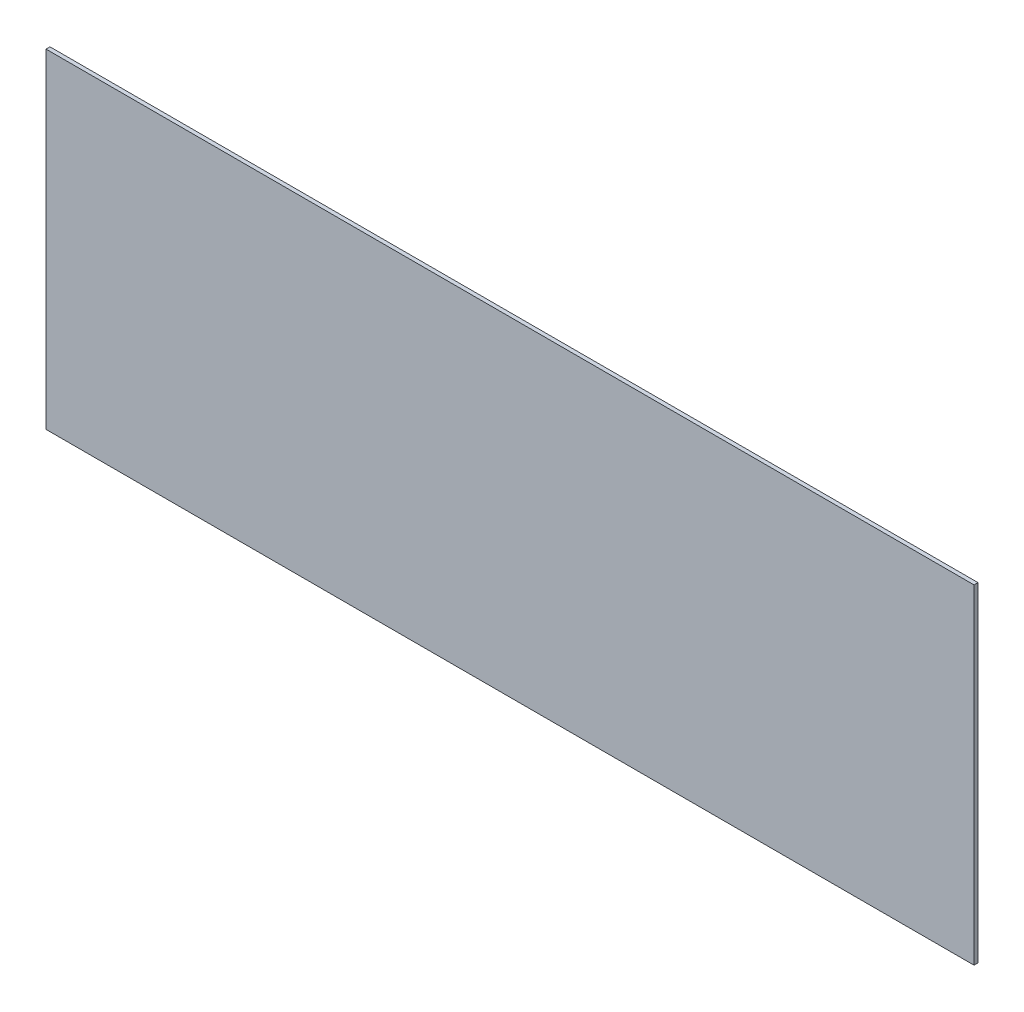
from build123d import *

# Parameters (mm, degrees)
SKETCH1_W           = 745
SKETCH1_H           = 264.4
BOSS_EXTRUDE1_DEPTH = 3.175


with BuildPart() as part:
    # Sketch1 → Boss-Extrude1 (new body)
    with BuildSketch(Plane.XY):
        Rectangle(SKETCH1_W, SKETCH1_H)
    extrude(amount=BOSS_EXTRUDE1_DEPTH)


solid = part.part
